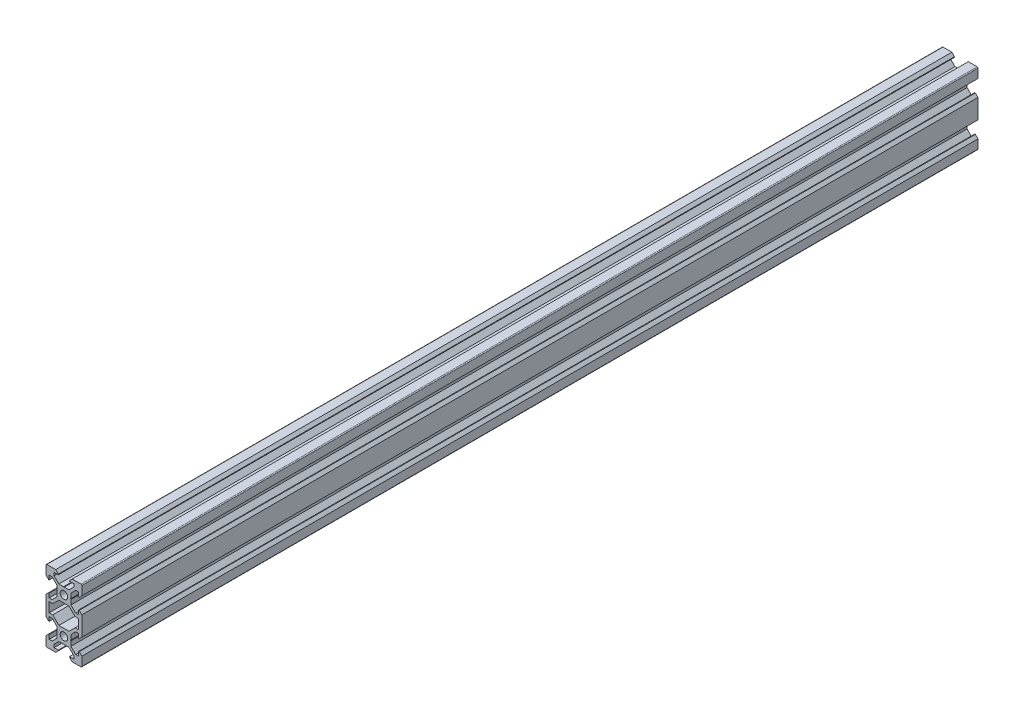
from build123d import *

# Parameters (mm, degrees)
SKETCH1_R           = 2.1
BOSS_EXTRUDE1_DEPTH = 500


with BuildPart() as part:
    # Sketch1 → Boss-Extrude1 (new body)
    with BuildSketch(Plane(origin=(0, 0, 0), x_dir=(-1, 0, 0), z_dir=(0, 0, -1))):
        with BuildLine():
            Line((-3.9, 9.79), (-3.9, 7.160660172))
            Line((-3.9, 7.160660172), (-6.560660172, 4.5))
            Line((-6.560660172, 4.5), (-8.2, 4.5))
            Line((-8.2, 4.5), (-8.2, 6.875))
            Line((-8.2, 6.875), (-8.545, 6.875))
            Line((-8.545, 6.875), (-10, 5.42))
            Line((-10, 5.42), (-10, -5.42))
            Line((-10, -5.42), (-8.545, -6.875))
            Line((-8.545, -6.875), (-8.2, -6.875))
            Line((-8.2, -6.875), (-8.2, -4.5))
            Line((-8.2, -4.5), (-6.560660172, -4.5))
            Line((-6.560660172, -4.5), (-3.9, -7.160660172))
            Line((-3.9, -7.160660172), (-3.9, -9.79))
            Line((-3.9, -9.79), (-3.69, -10))
            Line((-3.69, -10), (-3.9, -10.21))
            Line((-3.9, -10.21), (-3.9, -12.839339828))
            Line((-3.9, -12.839339828), (-6.560660172, -15.5))
            Line((-6.560660172, -15.5), (-8.2, -15.5))
            Line((-8.2, -15.5), (-8.2, -13.125))
            Line((-8.2, -13.125), (-8.545, -13.125))
            Line((-8.545, -13.125), (-10, -14.58))
            Line((-10, -14.58), (-10, -19.5))
            ThreePointArc((-10, -19.5), (-9.853553391, -19.853553391), (-9.5, -20))
            Line((-9.5, -20), (-4.58, -20))
            Line((-4.58, -20), (-3.125, -18.545))
            Line((-3.125, -18.545), (-3.125, -18.2))
            Line((-3.125, -18.2), (-5.5, -18.2))
            Line((-5.5, -18.2), (-5.5, -16.560660172))
            Line((-5.5, -16.560660172), (-2.839339828, -13.9))
            Line((-2.839339828, -13.9), (-0.21, -13.9))
            Line((-0.21, -13.9), (0, -13.69))
            Line((0, -13.69), (0.21, -13.9))
            Line((0.21, -13.9), (2.839339828, -13.9))
            Line((2.839339828, -13.9), (5.5, -16.560660172))
            Line((5.5, -16.560660172), (5.5, -18.2))
            Line((5.5, -18.2), (3.125, -18.2))
            Line((3.125, -18.2), (3.125, -18.545))
            Line((3.125, -18.545), (4.58, -20))
            Line((4.58, -20), (9.5, -20))
            ThreePointArc((9.5, -20), (9.853553391, -19.853553391), (10, -19.5))
            Line((10, -19.5), (10, -14.58))
            Line((10, -14.58), (8.545, -13.125))
            Line((8.545, -13.125), (8.2, -13.125))
            Line((8.2, -13.125), (8.2, -15.5))
            Line((8.2, -15.5), (6.560660172, -15.5))
            Line((6.560660172, -15.5), (3.9, -12.839339828))
            Line((3.9, -12.839339828), (3.9, -10.21))
            Line((3.9, -10.21), (3.69, -10))
            Line((3.69, -10), (3.9, -9.79))
            Line((3.9, -9.79), (3.9, -7.160660172))
            Line((3.9, -7.160660172), (6.560660172, -4.5))
            Line((6.560660172, -4.5), (8.2, -4.5))
            Line((8.2, -4.5), (8.2, -6.875))
            Line((8.2, -6.875), (8.545, -6.875))
            Line((8.545, -6.875), (10, -5.42))
            Line((10, -5.42), (10, 5.42))
            Line((10, 5.42), (8.545, 6.875))
            Line((8.545, 6.875), (8.2, 6.875))
            Line((8.2, 6.875), (8.2, 4.5))
            Line((8.2, 4.5), (6.560660172, 4.5))
            Line((6.560660172, 4.5), (3.9, 7.160660172))
            Line((3.9, 7.160660172), (3.9, 9.79))
            Line((3.9, 9.79), (3.69, 10))
            Line((3.69, 10), (3.9, 10.21))
            Line((3.9, 10.21), (3.9, 12.839339828))
            Line((3.9, 12.839339828), (6.560660172, 15.5))
            Line((6.560660172, 15.5), (8.2, 15.5))
            Line((8.2, 15.5), (8.2, 13.125))
            Line((8.2, 13.125), (8.545, 13.125))
            Line((8.545, 13.125), (10, 14.58))
            Line((10, 14.58), (10, 19.5))
            ThreePointArc((10, 19.5), (9.853553391, 19.853553391), (9.5, 20))
            Line((9.5, 20), (4.58, 20))
            Line((4.58, 20), (3.125, 18.545))
            Line((3.125, 18.545), (3.125, 18.2))
            Line((3.125, 18.2), (5.5, 18.2))
            Line((5.5, 18.2), (5.5, 16.560660172))
            Line((5.5, 16.560660172), (2.839339828, 13.9))
            Line((2.839339828, 13.9), (0.21, 13.9))
            Line((0.21, 13.9), (0, 13.69))
            Line((0, 13.69), (-0.21, 13.9))
            Line((-0.21, 13.9), (-2.839339828, 13.9))
            Line((-2.839339828, 13.9), (-5.5, 16.560660172))
            Line((-5.5, 16.560660172), (-5.5, 18.2))
            Line((-5.5, 18.2), (-3.125, 18.2))
            Line((-3.125, 18.2), (-3.125, 18.545))
            Line((-3.125, 18.545), (-4.58, 20))
            Line((-4.58, 20), (-9.5, 20))
            ThreePointArc((-9.5, 20), (-9.853553391, 19.853553391), (-10, 19.5))
            Line((-10, 19.5), (-10, 14.58))
            Line((-10, 14.58), (-8.545, 13.125))
            Line((-8.545, 13.125), (-8.2, 13.125))
            Line((-8.2, 13.125), (-8.2, 15.5))
            Line((-8.2, 15.5), (-6.560660172, 15.5))
            Line((-6.560660172, 15.5), (-3.9, 12.839339828))
            Line((-3.9, 12.839339828), (-3.9, 10.21))
            Line((-3.9, 10.21), (-3.69, 10))
            Line((-3.69, 10), (-3.9, 9.79))
        make_face()
        with Locations((0, 10)):
            Circle(SKETCH1_R, mode=Mode.SUBTRACT)
        with Locations((0, -10)):
            Circle(SKETCH1_R, mode=Mode.SUBTRACT)
        Polygon((6.239339828, -2.7), (2.839339828, -6.1), (-2.839339828, -6.1), (-6.239339828, -2.7), (-8.2, -2.7), (-8.2, 2.7), (-6.239339828, 2.7), (-2.839339828, 6.1), (2.839339828, 6.1), (6.239339828, 2.7), (8.2, 2.7), (8.2, -2.7), align=None, mode=Mode.SUBTRACT)
    extrude(amount=-BOSS_EXTRUDE1_DEPTH)


solid = part.part
